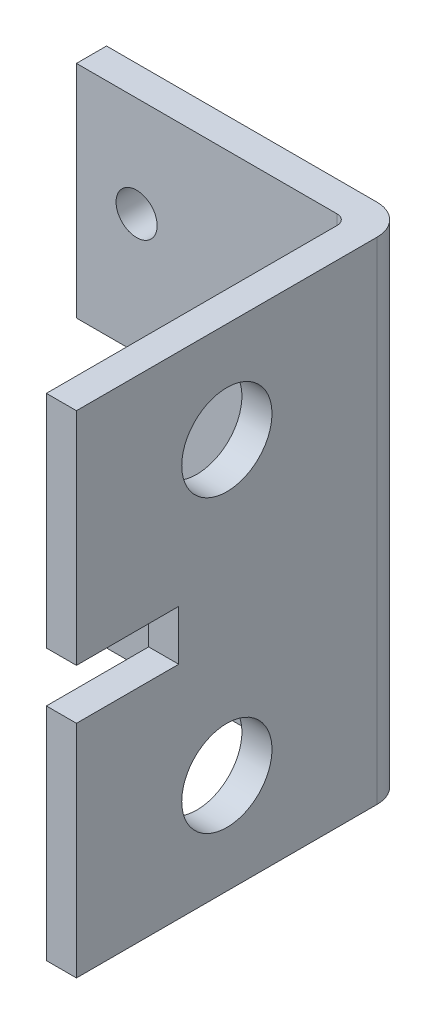
from build123d import *

# Parameters (mm, degrees)
SKETCH2_W               = 27
SKETCH2_H               = 49
SKETCH2_R               = 2.05
BOSS_EXTRUDE1_DEPTH     = 3
BOSS_EXTRUDE2_DEPTH     = 49
SKETCH5_R               = 4.5
CUT_EXTRUDE1_DEPTH      = 4
FILLET1_R               = 1
SKETCH6_W               = 13.2
SKETCH6_H               = 5
CUT_EXTRUDE2_DEPTH      = 4
SKETCH7_W               = 10.2
SKETCH7_H               = 5
CUT_EXTRUDE3_DEPTH      = 28
CUT_EXTRUDE3_DEPTH_BACK = 4


with BuildPart() as part:
    # Sketch2 → Boss-Extrude1 (new body)
    with BuildSketch(Plane.XY):
        with Locations((13.5, 24.5)):
            Rectangle(SKETCH2_W, SKETCH2_H)
        with Locations((6, 39)):
            Circle(SKETCH2_R, mode=Mode.SUBTRACT)
        with Locations((21, 39)):
            Circle(SKETCH2_R, mode=Mode.SUBTRACT)
        with Locations((6, 10)):
            Circle(SKETCH2_R, mode=Mode.SUBTRACT)
        with Locations((21, 10)):
            Circle(SKETCH2_R, mode=Mode.SUBTRACT)
    extrude(amount=BOSS_EXTRUDE1_DEPTH)

    # Sketch4 → Boss-Extrude2 (add)
    with BuildSketch(Plane(origin=(0, 49, 0), x_dir=(1, 0, 0), z_dir=(0, 1, 0))):
        with BuildLine():
            Line((30, -3), (30, -33))
            Line((30, -33), (27, -33))
            Line((27, -33), (27, 0))
            ThreePointArc((27, 0), (29.121320344, -0.878679656), (30, -3))
        make_face()
    extrude(amount=-BOSS_EXTRUDE2_DEPTH)

    # Sketch5 → Cut-Extrude1 (cut, through all)
    with BuildSketch(Plane.ZY.offset(-27)):
        with Locations((18, 39)):
            Circle(SKETCH5_R)
        with Locations((18, 10)):
            Circle(SKETCH5_R)
    extrude(amount=-CUT_EXTRUDE1_DEPTH, mode=Mode.SUBTRACT)

    # Fillet1
    fillet1_edges = [part.edges().sort_by_distance(p)[0] for p in [
        (27, 24.5, 3),
    ]]
    fillet(fillet1_edges, radius=FILLET1_R)

    # Sketch6 → Cut-Extrude2 (cut, through all)
    with BuildSketch(Plane.XY.offset(3)):
        with Locations((3.6, 24.5)):
            Rectangle(SKETCH6_W, SKETCH6_H)
    extrude(amount=-CUT_EXTRUDE2_DEPTH, mode=Mode.SUBTRACT)

    # Sketch7 → Cut-Extrude3 (cut, two sides)
    with BuildSketch(Plane.ZY.offset(-27)) as cut_extrude3_sk:
        with Locations((27.9, 24.5)):
            Rectangle(SKETCH7_W, SKETCH7_H)
    extrude(amount=CUT_EXTRUDE3_DEPTH, mode=Mode.SUBTRACT)
    extrude(cut_extrude3_sk.sketch, amount=-CUT_EXTRUDE3_DEPTH_BACK, mode=Mode.SUBTRACT)


solid = part.part
